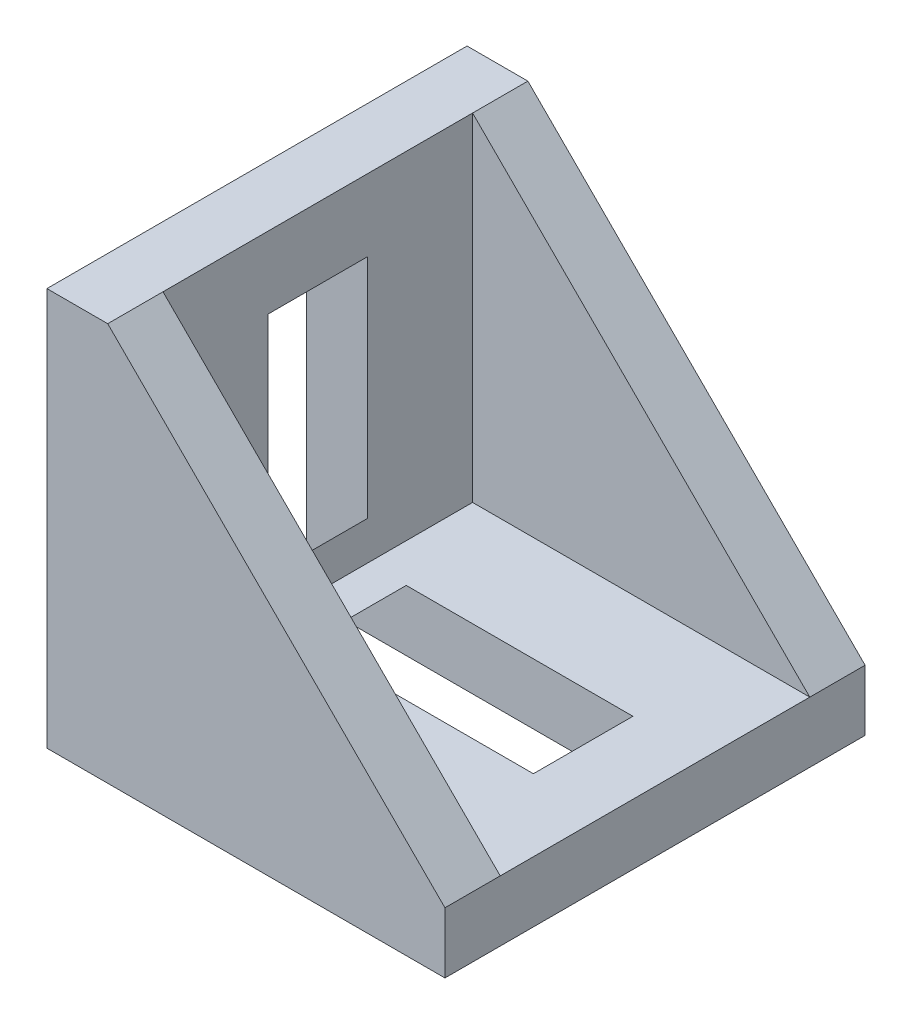
from build123d import *

# Parameters (mm, degrees)
BOSS_EXTRUDE1_DEPTH = 19
CUT_EXTRUDE1_DEPTH  = 14
CUT_EXTRUDE2_DEPTH  = 4.5
BOSS_EXTRUDE2_DEPTH = 4


with BuildPart() as part:
    # Sketch1 → Boss-Extrude1 (new body, symmetric)
    with BuildSketch(Plane.XY):
        Polygon((0, 0), (0, 36), (5.5, 36), (36, 5.5), (36, 0), align=None)
    extrude(amount=BOSS_EXTRUDE1_DEPTH, both=True)

    # Sketch2 → Cut-Extrude1 (cut, symmetric)
    with BuildSketch(Plane.XY):
        Polygon((5.5, 36), (5.5, 5.5), (36, 5.5), align=None)
    extrude(amount=CUT_EXTRUDE1_DEPTH, both=True, mode=Mode.SUBTRACT)

    # Sketch3 → Cut-Extrude2 (cut, symmetric)
    with BuildSketch(Plane.XY):
        Polygon((0, 29.5), (5.5, 29.5), (5.5, 9), (0, 3.5), align=None)
        Polygon((9, 5.5), (29.5, 5.5), (29.5, 0), (3.5, 0), align=None)
    extrude(amount=CUT_EXTRUDE2_DEPTH, both=True, mode=Mode.SUBTRACT)

    # Sketch4 → Boss-Extrude2 (add, symmetric)
    with BuildSketch(Plane.XY):
        Polygon((0.714757963, -2.5), (-0.201070953, -1.5696698), (1.234750477, 0), (3.535533906, 0), align=None)
        Polygon((0, 3.535533906), (-2.5, 0.714757963), (-1.5696698, -0.201070953), (0, 1.234750477), align=None)
        Polygon((0, 35.3), (0, 32.999216572), (-1.5696698, 31.563395141), (-2.5, 32.479224057), align=None)
        Polygon((32.999216572, 0), (31.563395141, -1.5696698), (32.479224057, -2.5), (35.3, 0), align=None)
    extrude(amount=BOSS_EXTRUDE2_DEPTH, both=True)


solid = part.part
